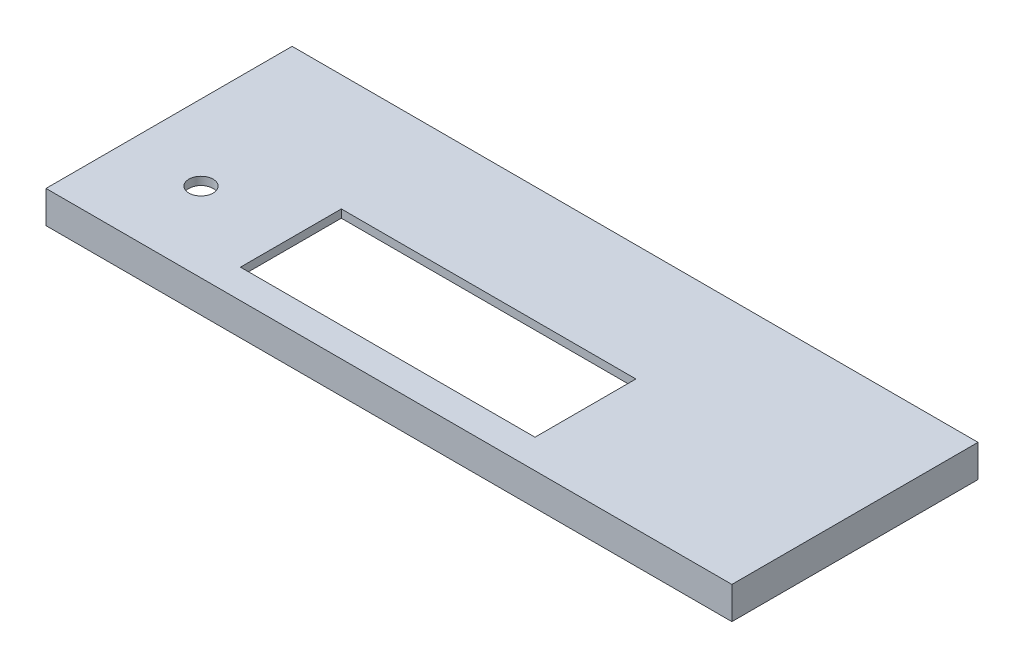
from build123d import *

# Parameters (mm, degrees)
BOSS_EXTRUDE1_DEPTH = 8
SKETCH9_W           = 166
SKETCH9_H           = 57
CUT_EXTRUDE5_DEPTH  = 6
SKETCH10_W          = 10
SKETCH10_H          = 1
CUT_EXTRUDE6_DEPTH  = 6
BOSS_EXTRUDE4_DEPTH = 130
SKETCH13_R          = 3
SKETCH13_W          = 73
SKETCH13_H          = 25
CUT_EXTRUDE7_DEPTH  = 130


with BuildPart() as part:
    # Sketch1 → Boss-Extrude1 (new body)
    with BuildSketch(Plane(origin=(0, 0, 0), x_dir=(1, 0, 0), z_dir=(0, 1, 0))):
        Polygon((0, 0), (88, 0), (170, 0), (170, 41), (170, 61), (0, 61), align=None)
    extrude(amount=BOSS_EXTRUDE1_DEPTH)

    # Sketch9 → Cut-Extrude5 (cut)
    with BuildSketch(Plane.XZ):
        with Locations((85, -30.5)):
            Rectangle(SKETCH9_W, SKETCH9_H)
    extrude(amount=-CUT_EXTRUDE5_DEPTH, mode=Mode.SUBTRACT)

    # Sketch10 → Cut-Extrude6 (cut)
    with BuildSketch(Plane.XZ):
        with Locations((27, -1.5)):
            Rectangle(SKETCH10_W, SKETCH10_H)
        with Locations((27, -59.5)):
            Rectangle(SKETCH10_W, SKETCH10_H)
        with Locations((143, -59.5)):
            Rectangle(SKETCH10_W, SKETCH10_H)
        with Locations((143, -1.5)):
            Rectangle(SKETCH10_W, SKETCH10_H)
    extrude(amount=-CUT_EXTRUDE6_DEPTH, mode=Mode.SUBTRACT)

    # Sketch11 → Boss-Extrude4 (add)
    with BuildSketch(Plane(origin=(22, 0, 0), x_dir=(0, 0, -1), z_dir=(1, 0, 0))):
        Polygon((1, 3.292893219), (1, 4.5), (1.353553391, 4.146446609), (1.353553391, 3.646446609), align=None)
        Polygon((60, 3.292893219), (60, 4.5), (59.646446609, 4.146446609), (59.646446609, 3.646446609), align=None)
    extrude(amount=BOSS_EXTRUDE4_DEPTH)

    # Sketch13 → Cut-Extrude7 (cut)
    with BuildSketch(Plane(origin=(0, 8, 0), x_dir=(1, 0, 0), z_dir=(0, 1, 0))):
        with Locations((18.71505207, 19.7)):
            Circle(SKETCH13_R)
        with Locations((77.5, 19.7)):
            Rectangle(SKETCH13_W, SKETCH13_H)
    extrude(amount=-CUT_EXTRUDE7_DEPTH, mode=Mode.SUBTRACT)


solid = part.part
